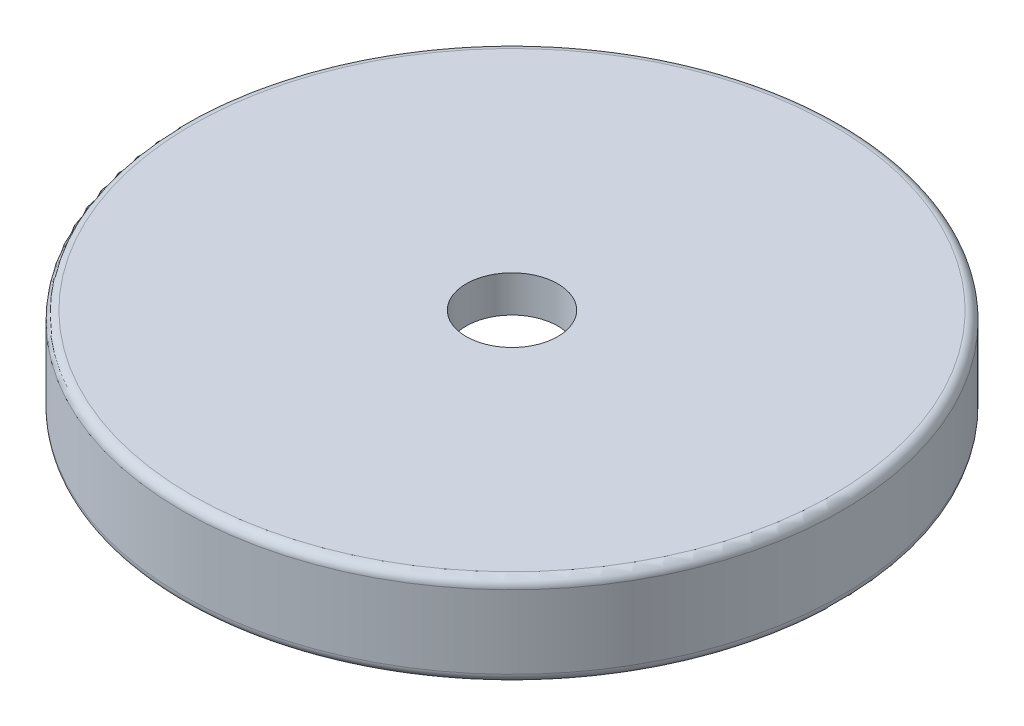
from build123d import *

# Parameters (mm, degrees)
SKETCH1_R           = 18
SKETCH1_R_2         = 2.5
BOSS_EXTRUDE3_DEPTH = 2
SKETCH3_R           = 18
SKETCH3_R_2         = 15
BOSS_EXTRUDE4_DEPTH = 3
FILLET1_R           = 0.5
FILLET2_R           = 0.5
FILLET3_R           = 0.5
FILLET4_R           = 0.1


with BuildPart() as part:
    # Sketch1 → Boss-Extrude3 (new body)
    with BuildSketch(Plane(origin=(0, 0, 0), x_dir=(1, 0, 0), z_dir=(0, 1, 0))):
        Circle(SKETCH1_R)
        Circle(SKETCH1_R_2, mode=Mode.SUBTRACT)
    extrude(amount=BOSS_EXTRUDE3_DEPTH)

    # Sketch3 → Boss-Extrude4 (add)
    with BuildSketch(Plane.XZ):
        Circle(SKETCH3_R)
        Circle(SKETCH3_R_2, mode=Mode.SUBTRACT)
    extrude(amount=BOSS_EXTRUDE4_DEPTH)

    # Sketch4 → Cut-Revolve1 (revolve, cut)
    with BuildSketch(Plane.XY):
        with BuildLine():
            Line((15, 0), (15, -2))
            ThreePointArc((15, -2), (16, -1), (15, 0))
        make_face()
    revolve(axis=Axis((0, 0, 0), (0, 1, 0)), mode=Mode.SUBTRACT)

    # Fillet1
    fillet1_edges = [part.edges().sort_by_distance(p)[0] for p in [
        (-15, -2, 0),
    ]]
    fillet(fillet1_edges, radius=FILLET1_R)

    # Fillet2
    fillet2_edges = [part.edges().sort_by_distance(p)[0] for p in [
        (-18, -3, 0),
    ]]
    fillet(fillet2_edges, radius=FILLET2_R)

    # Fillet3
    fillet3_edges = [part.edges().sort_by_distance(p)[0] for p in [
        (-18, 2, 0),
    ]]
    fillet(fillet3_edges, radius=FILLET3_R)

    # Fillet4
    fillet4_edges = [part.edges().sort_by_distance(p)[0] for p in [
        (-15, -3, 0),
    ]]
    fillet(fillet4_edges, radius=FILLET4_R)


solid = part.part
